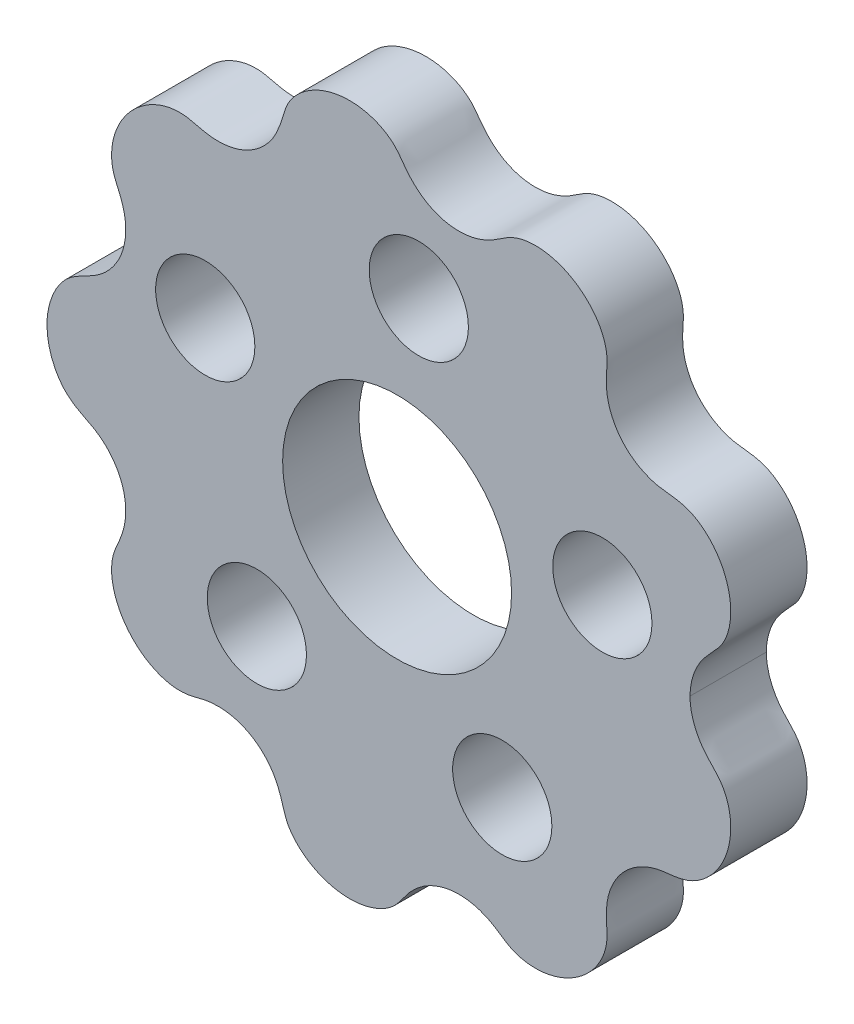
from build123d import *

# Parameters (mm, degrees)
SKETCH_1_R          = 6
EXTRUDE_1_DEPTH     = 4
SKETCH_2_R          = 2.6
CUT_EXTRUDE_1_DEPTH = 4
CUT_EXTRUDE_2_DEPTH = 20


with BuildPart() as part:
    # 草图1 → 凸台-拉伸1 (new body)
    with BuildSketch(Plane.XY):
        with BuildLine():
            add(Edge.make_bspline(
                [(15.500012348, 0), (15.500645056, -0.110945579), (15.512244846, -0.333708134), (15.56080203, -0.665755528), (15.686127898, -1.095543655), (15.861199112, -1.486039477), (16.07234193, -1.834330022), (16.308329582, -2.140469508), (16.554971715, -2.411142214), (16.831486095, -2.680258156), (17.09417526, -2.991849508), (17.318310393, -3.376025869), (17.493414378, -3.823344747), (17.600433494, -4.292089882), (17.644680388, -4.770032347), (17.628438972, -5.345442688), (17.511433644, -6.009073131), (17.278169805, -6.64415923), (16.937084367, -7.226794616), (16.575099706, -7.677002473), (16.230913701, -8.012641761), (15.844660445, -8.299708218), (15.420312172, -8.526649182), (15.041200514, -8.657072274), (14.727411454, -8.716357887), (14.475396299, -8.743253426), (14.287840755, -8.761378707), (14.053780681, -8.78754437), (13.774476702, -8.831854759), (13.435631669, -8.913065786), (13.046475639, -9.054518572), (12.661901116, -9.252728428), (12.293359231, -9.51266783), (11.884847729, -9.896613005), (11.554140655, -10.350120451), (11.313867772, -10.855204363), (11.174534113, -11.372142401), (11.117745702, -11.772455328), (11.105580832, -12.15666376), (11.123538194, -12.5208422), (11.161632052, -12.902801573), (11.156513572, -13.307609415), (11.077036824, -13.743232828), (10.919642656, -14.196363601), (10.697252801, -14.621676142), (10.421334976, -15.013428486), (10.038624904, -15.438358823), (9.519879354, -15.869092133), (8.927602604, -16.20436412), (8.28296764, -16.42933205), (7.709837342, -16.5363703), (7.233957857, -16.56641967), (6.757848942, -16.533391128), (6.291654266, -16.431205387), (5.918806602, -16.283724895), (5.639283103, -16.121815596), (5.429189454, -15.97884859), (5.275520034, -15.873677026), (5.08115039, -15.745699964), (4.840646937, -15.603383924), (4.528246746, -15.449991133), (4.135785298, -15.310075701), (3.706914344, -15.21711311), (3.247358332, -15.184013627), (2.683616627, -15.224313987), (2.140357034, -15.368005564), (1.638214991, -15.606714116), (1.208281686, -15.914761357), (0.913691367, -16.184992229), (0.662262597, -16.470572297), (0.445813505, -16.759694454), (0.230880732, -17.073039045), (-0.033157525, -17.373910711), (-0.368153716, -17.648605439), (-0.768020687, -17.886570031), (-1.197742019, -18.065543824), (-1.646249026, -18.188095665), (-2.200564338, -18.271695312), (-2.860263372, -18.275882878), (-3.513707318, -18.16532789), (-4.137283921, -17.943611616), (-4.64139611, -17.677469631), (-5.034364446, -17.405892441), (-5.388929067, -17.084733218), (-5.692750717, -16.715459856), (-5.917926574, -16.335896793), (-6.063844811, -15.959590707), (-6.159018515, -15.588889837), (-6.264745664, -15.241187207), (-6.405191317, -14.884637032), (-6.592424605, -14.527795683), (-6.83291701, -14.179916823), (-7.131479128, -13.852998257), (-7.562146174, -13.49483271), (-8.05706918, -13.219964643), (-8.59778426, -13.042242616), (-9.141509134, -12.970482269), (-9.554297958, -12.968980709), (-9.897259393, -13.006571791), (-10.169778374, -13.05791326), (-10.394441717, -13.111355966), (-10.573432363, -13.157274149), (-10.81755935, -13.219185953), (-11.132458027, -13.275500509), (-11.53518174, -13.287679567), (-12.015391816, -13.223776598), (-12.480698875, -13.088905012), (-12.923149037, -12.892864291), (-13.423381512, -12.593604406), (-13.948700915, -12.161386427), (-14.388934988, -11.642342598), (-14.728215283, -11.056761927), (-14.939700346, -10.525268324), (-15.060904211, -10.068979736), (-15.12238338, -9.600221994), (-15.115836901, -9.127737278), (-15.042892864, -8.692577333), (-14.908282623, -8.306673996), (-14.740220709, -7.957832439), (-14.597927538, -7.618965375), (-14.477542028, -7.250368161), (-14.394399075, -6.850773435), (-14.350409232, -6.3116245), (-14.407649225, -5.749269062), (-14.569528538, -5.205860879), (-14.829729033, -4.703130394), (-15.0936632, -4.33263276), (-15.391939241, -4.017591627), (-15.711193803, -3.756589186), (-16.00068685, -3.568915687), (-16.244479863, -3.436538423), (-16.493001037, -3.313257547), (-16.763479178, -3.188383092), (-17.082150332, -3.007532312), (-17.425261485, -2.724866456), (-17.740378416, -2.369698261), (-18.000745754, -1.972409345), (-18.206889112, -1.545151716), (-18.392385524, -1.002108371), (-18.473867602, -0.558465841), (-18.499033816, -0.222693371), (-18.499997323, 0)],
                knots=[0.122949625, 0.122949625, 0.122949625, 0.122949625, 0.122949625, 0.128396608, 0.133889369, 0.139372934, 0.144856498, 0.14934603, 0.153835562, 0.158325094, 0.162814627, 0.168292898, 0.17377117, 0.180047296, 0.186323423, 0.191803347, 0.197283271, 0.208243119, 0.21926116, 0.22477018, 0.2302792, 0.236541517, 0.242803834, 0.24831051, 0.253817186, 0.256129694, 0.258442201, 0.260754709, 0.263067216, 0.267692231, 0.272317246, 0.27783198, 0.283346713, 0.288866947, 0.294387181, 0.30526522, 0.310695103, 0.316124986, 0.320596912, 0.325068837, 0.329540762, 0.334012688, 0.339439896, 0.344867103, 0.351176165, 0.357485227, 0.362911415, 0.368337604, 0.379189982, 0.390444514, 0.39607178, 0.401699045, 0.407747404, 0.413795762, 0.419420549, 0.425045336, 0.427330399, 0.429615462, 0.431900526, 0.434185589, 0.438755715, 0.443325841, 0.448958262, 0.454590682, 0.460230133, 0.465869584, 0.476610964, 0.481971727, 0.487332489, 0.491763254, 0.49619402, 0.500624785, 0.505055551, 0.510412088, 0.515768625, 0.521798169, 0.527827714, 0.53318598, 0.538544247, 0.54926078, 0.560078777, 0.565487776, 0.570896775, 0.577186447, 0.583476118, 0.58888578, 0.594295441, 0.598753624, 0.603211806, 0.607669989, 0.612128172, 0.617539855, 0.622951539, 0.628373602, 0.633795666, 0.644955124, 0.650528285, 0.656101446, 0.660636549, 0.665171653, 0.667439204, 0.669706756, 0.671974307, 0.674241859, 0.679807823, 0.685373788, 0.69165463, 0.697935473, 0.703503519, 0.709071566, 0.72020766, 0.731178828, 0.736664412, 0.742149996, 0.748227574, 0.754305152, 0.75979058, 0.765276008, 0.769783463, 0.774290918, 0.778798372, 0.783305827, 0.78879334, 0.794280853, 0.80527863, 0.810847908, 0.816417186, 0.821978545, 0.827539905, 0.832078373, 0.83661684, 0.838886074, 0.841155308, 0.845693775, 0.851249605, 0.856805435, 0.86286691, 0.868928385, 0.874484925, 0.880041465, 0.890974567, 0.890974567, 0.890974567, 0.890974567, 0.890974567], degree=4))
            add(Edge.make_bspline(
                [(15.500012348, 0), (15.500645056, 0.110945579), (15.512244846, 0.333708134), (15.56080203, 0.665755528), (15.686127898, 1.095543655), (15.861199112, 1.486039477), (16.07234193, 1.834330022), (16.308329582, 2.140469507), (16.554971715, 2.411142214), (16.831486095, 2.680258156), (17.09417526, 2.991849508), (17.318310393, 3.376025869), (17.493414378, 3.823344747), (17.600433494, 4.292089882), (17.644680388, 4.770032347), (17.628438972, 5.345442688), (17.511433644, 6.009073131), (17.278169805, 6.64415923), (16.937084367, 7.226794616), (16.575099706, 7.677002473), (16.230913701, 8.012641761), (15.844660445, 8.299708218), (15.420312172, 8.526649182), (15.041200514, 8.657072274), (14.727411454, 8.716357887), (14.475396299, 8.743253426), (14.287840755, 8.761378707), (14.053780681, 8.78754437), (13.774476702, 8.831854759), (13.435631669, 8.913065786), (13.046475639, 9.054518572), (12.661901116, 9.252728428), (12.293359231, 9.51266783), (11.884847729, 9.896613005), (11.554140655, 10.350120451), (11.313867772, 10.855204363), (11.174534113, 11.372142401), (11.117745702, 11.772455328), (11.105580832, 12.15666376), (11.123538194, 12.5208422), (11.161632052, 12.902801573), (11.156513572, 13.307609415), (11.077036824, 13.743232827), (10.919642656, 14.196363601), (10.697252801, 14.621676142), (10.421334976, 15.013428486), (10.038624904, 15.438358823), (9.519879354, 15.869092133), (8.927602604, 16.20436412), (8.28296764, 16.42933205), (7.709837342, 16.5363703), (7.233957857, 16.56641967), (6.757848942, 16.533391128), (6.291654266, 16.431205387), (5.918806602, 16.283724895), (5.639283102, 16.121815596), (5.429189454, 15.97884859), (5.275520034, 15.873677026), (5.08115039, 15.745699964), (4.840646937, 15.603383924), (4.528246746, 15.449991133), (4.135785298, 15.310075701), (3.706914344, 15.21711311), (3.247358332, 15.184013627), (2.683616627, 15.224313987), (2.140357034, 15.368005564), (1.638214991, 15.606714115), (1.208281686, 15.914761357), (0.913691367, 16.184992229), (0.662262596, 16.470572297), (0.445813505, 16.759694454), (0.230880731, 17.073039045), (-0.033157525, 17.373910711), (-0.368153716, 17.648605439), (-0.768020687, 17.886570031), (-1.197742019, 18.065543824), (-1.646249026, 18.188095665), (-2.200564338, 18.271695312), (-2.860263372, 18.275882877), (-3.513707318, 18.165327889), (-4.137283921, 17.943611616), (-4.64139611, 17.677469631), (-5.034364446, 17.405892441), (-5.388929067, 17.084733218), (-5.692750717, 16.715459856), (-5.917926574, 16.335896793), (-6.063844811, 15.959590707), (-6.159018515, 15.588889837), (-6.264745664, 15.241187207), (-6.405191317, 14.884637032), (-6.592424605, 14.527795683), (-6.83291701, 14.179916823), (-7.131479128, 13.852998256), (-7.562146174, 13.49483271), (-8.05706918, 13.219964643), (-8.59778426, 13.042242616), (-9.141509134, 12.970482269), (-9.554297958, 12.968980709), (-9.897259393, 13.006571791), (-10.169778374, 13.05791326), (-10.394441717, 13.111355966), (-10.573432363, 13.157274149), (-10.81755935, 13.219185953), (-11.132458027, 13.275500509), (-11.53518174, 13.287679567), (-12.015391816, 13.223776598), (-12.480698875, 13.088905011), (-12.923149037, 12.892864291), (-13.423381512, 12.593604406), (-13.948700915, 12.161386427), (-14.388934988, 11.642342598), (-14.728215283, 11.056761927), (-14.939700346, 10.525268324), (-15.060904211, 10.068979736), (-15.12238338, 9.600221993), (-15.115836901, 9.127737278), (-15.042892864, 8.692577333), (-14.908282623, 8.306673996), (-14.740220709, 7.957832438), (-14.597927538, 7.618965375), (-14.477542028, 7.250368161), (-14.394399075, 6.850773435), (-14.350409232, 6.3116245), (-14.407649225, 5.749269062), (-14.569528538, 5.205860879), (-14.829729033, 4.703130394), (-15.0936632, 4.33263276), (-15.391939241, 4.017591627), (-15.711193803, 3.756589186), (-16.00068685, 3.568915687), (-16.244479863, 3.436538423), (-16.493001037, 3.313257547), (-16.763479178, 3.188383092), (-17.082150332, 3.007532312), (-17.425261485, 2.724866456), (-17.740378416, 2.369698261), (-18.000745754, 1.972409345), (-18.206889112, 1.545151716), (-18.392385523, 1.002108371), (-18.473867602, 0.558465841), (-18.499033816, 0.222693371), (-18.499997323, 0)],
                knots=[0.122949625, 0.122949625, 0.122949625, 0.122949625, 0.122949625, 0.128396608, 0.133889369, 0.139372934, 0.144856498, 0.14934603, 0.153835562, 0.158325094, 0.162814627, 0.168292898, 0.17377117, 0.180047296, 0.186323423, 0.191803347, 0.197283271, 0.208243119, 0.21926116, 0.22477018, 0.2302792, 0.236541517, 0.242803834, 0.24831051, 0.253817186, 0.256129694, 0.258442201, 0.260754709, 0.263067216, 0.267692231, 0.272317246, 0.27783198, 0.283346713, 0.288866947, 0.294387181, 0.30526522, 0.310695103, 0.316124986, 0.320596912, 0.325068837, 0.329540762, 0.334012688, 0.339439896, 0.344867103, 0.351176165, 0.357485227, 0.362911415, 0.368337604, 0.379189982, 0.390444514, 0.39607178, 0.401699045, 0.407747404, 0.413795762, 0.419420549, 0.425045336, 0.427330399, 0.429615462, 0.431900526, 0.434185589, 0.438755715, 0.443325841, 0.448958262, 0.454590682, 0.460230133, 0.465869584, 0.476610964, 0.481971727, 0.487332489, 0.491763254, 0.49619402, 0.500624785, 0.505055551, 0.510412088, 0.515768625, 0.521798169, 0.527827714, 0.53318598, 0.538544247, 0.54926078, 0.560078777, 0.565487776, 0.570896775, 0.577186447, 0.583476118, 0.58888578, 0.594295441, 0.598753624, 0.603211806, 0.607669989, 0.612128172, 0.617539855, 0.622951539, 0.628373602, 0.633795666, 0.644955124, 0.650528285, 0.656101446, 0.660636549, 0.665171653, 0.667439204, 0.669706756, 0.671974307, 0.674241859, 0.679807823, 0.685373788, 0.69165463, 0.697935473, 0.703503519, 0.709071566, 0.72020766, 0.731178828, 0.736664412, 0.742149996, 0.748227574, 0.754305152, 0.75979058, 0.765276008, 0.769783463, 0.774290918, 0.778798372, 0.783305827, 0.78879334, 0.794280853, 0.80527863, 0.810847908, 0.816417186, 0.821978545, 0.827539905, 0.832078373, 0.83661684, 0.838886074, 0.841155308, 0.845693775, 0.851249605, 0.856805435, 0.86286691, 0.868928385, 0.874484925, 0.880041465, 0.890974567, 0.890974567, 0.890974567, 0.890974567, 0.890974567], degree=4))
        make_face()
        Circle(SKETCH_1_R, mode=Mode.SUBTRACT)
    extrude(amount=EXTRUDE_1_DEPTH)

    # 草图2 → 切除-拉伸1 (cut)
    with BuildSketch(Plane.XY.offset(4)):
        with Locations((5.511431327, -9.519670411)):
            Circle(SKETCH_2_R)
        with Locations((-7.350618634, -8.183422615)):
            Circle(SKETCH_2_R)
        with Locations((-10.054363481, 4.46203709)):
            Circle(SKETCH_2_R)
        with Locations((1.136680267, 10.941113196)):
            Circle(SKETCH_2_R)
        with Locations((10.75687052, 2.29994274)):
            Circle(SKETCH_2_R)
    extrude(amount=-CUT_EXTRUDE_1_DEPTH, mode=Mode.SUBTRACT)

    # 草图3 → 切除-拉伸2 (cut)
    with BuildSketch(Plane.XY.offset(4)):
        with BuildLine():
            add(Edge.make_bspline(
                [(-18.499997323, 0), (-18.499033816, -0.222693371), (-18.473867602, -0.558465841), (-18.392385524, -1.002108371), (-18.206889112, -1.545151716), (-18.000745754, -1.972409345), (-17.740378416, -2.369698261), (-17.425261485, -2.724866456), (-17.082150332, -3.007532312), (-16.763479178, -3.188383092), (-16.493001037, -3.313257547), (-16.244479863, -3.436538423), (-16.00068685, -3.568915687), (-15.711193803, -3.756589186), (-15.391939241, -4.017591627), (-15.0936632, -4.33263276), (-14.829729033, -4.703130394), (-14.569528538, -5.205860879), (-14.407649225, -5.749269062), (-14.350409232, -6.3116245), (-14.394399075, -6.850773435), (-14.477542028, -7.250368161), (-14.597927538, -7.618965375), (-14.740220709, -7.957832439), (-14.908282623, -8.306673996), (-15.042892864, -8.692577333), (-15.115836901, -9.127737278), (-15.12238338, -9.600221994), (-15.060904211, -10.068979736), (-14.939700346, -10.525268324), (-14.728215283, -11.056761927), (-14.388934988, -11.642342598), (-13.948700915, -12.161386427), (-13.423381512, -12.593604406), (-12.923149037, -12.892864291), (-12.480698875, -13.088905012), (-12.015391816, -13.223776598), (-11.53518174, -13.287679567), (-11.132458027, -13.275500509), (-10.81755935, -13.219185953), (-10.573432363, -13.157274149), (-10.394441717, -13.111355966), (-10.169778374, -13.05791326), (-9.897259393, -13.006571791), (-9.554297958, -12.968980709), (-9.141509134, -12.970482269), (-8.59778426, -13.042242616), (-8.05706918, -13.219964643), (-7.562146174, -13.49483271), (-7.131479128, -13.852998257), (-6.83291701, -14.179916823), (-6.592424605, -14.527795683), (-6.405191317, -14.884637032), (-6.264745664, -15.241187207), (-6.159018515, -15.588889837), (-6.063844811, -15.959590707), (-5.917926574, -16.335896793), (-5.692750717, -16.715459856), (-5.388929067, -17.084733218), (-5.034364446, -17.405892441), (-4.64139611, -17.677469631), (-4.137283921, -17.943611616), (-3.513707318, -18.16532789), (-2.860263372, -18.275882878), (-2.200564338, -18.271695312), (-1.646249026, -18.188095665), (-1.197742019, -18.065543824), (-0.768020687, -17.886570031), (-0.368153716, -17.648605439), (-0.033157525, -17.373910711), (0.230880732, -17.073039045), (0.445813505, -16.759694454), (0.662262597, -16.470572297), (0.913691367, -16.184992229), (1.208281686, -15.914761357), (1.638214991, -15.606714116), (2.140357034, -15.368005564), (2.683616627, -15.224313987), (3.247358332, -15.184013627), (3.706914344, -15.21711311), (4.135785298, -15.310075701), (4.528246746, -15.449991133), (4.840646937, -15.603383924), (5.08115039, -15.745699964), (5.275520034, -15.873677026), (5.429189454, -15.97884859), (5.639283103, -16.121815596), (5.918806602, -16.283724895), (6.291654266, -16.431205387), (6.757848942, -16.533391128), (7.233957857, -16.56641967), (7.709837342, -16.5363703), (8.28296764, -16.42933205), (8.927602604, -16.20436412), (9.519879354, -15.869092133), (10.038624904, -15.438358823), (10.421334976, -15.013428486), (10.697252801, -14.621676142), (10.919642656, -14.196363601), (11.077036824, -13.743232828), (11.156513572, -13.307609415), (11.161632052, -12.902801573), (11.123538194, -12.5208422), (11.105580832, -12.15666376), (11.117745702, -11.772455328), (11.174534113, -11.372142401), (11.313867772, -10.855204363), (11.554140655, -10.350120451), (11.884847729, -9.896613005), (12.293359231, -9.51266783), (12.661901116, -9.252728428), (13.046475639, -9.054518572), (13.435631669, -8.913065786), (13.774476702, -8.831854759), (14.053780681, -8.78754437), (14.287840755, -8.761378707), (14.475396299, -8.743253426), (14.727411454, -8.716357887), (15.041200514, -8.657072274), (15.420312172, -8.526649182), (15.844660445, -8.299708218), (16.230913701, -8.012641761), (16.575099706, -7.677002473), (16.937084367, -7.226794616), (17.278169805, -6.64415923), (17.511433644, -6.009073131), (17.628438972, -5.345442688), (17.644680388, -4.770032347), (17.600433494, -4.292089882), (17.493414378, -3.823344747), (17.318310393, -3.376025869), (17.09417526, -2.991849508), (16.831486095, -2.680258156), (16.554971715, -2.411142214), (16.308329582, -2.140469508), (16.07234193, -1.834330022), (15.861199112, -1.486039477), (15.686127898, -1.095543655), (15.56080203, -0.665755528), (15.512244846, -0.333708134), (15.500645056, -0.110945579), (15.500012348, 0)],
                knots=[0.122949625, 0.122949625, 0.122949625, 0.122949625, 0.122949625, 0.133882727, 0.139439267, 0.144995807, 0.151057282, 0.157118757, 0.162674587, 0.168230417, 0.172768884, 0.175038118, 0.177307352, 0.181845819, 0.186384287, 0.191945647, 0.197507006, 0.203076284, 0.208645562, 0.219643339, 0.225130852, 0.230618365, 0.23512582, 0.239633274, 0.244140729, 0.248648184, 0.254133612, 0.25961904, 0.265696618, 0.271774196, 0.27725978, 0.282745364, 0.293716532, 0.304852626, 0.310420673, 0.315988719, 0.322269562, 0.328550404, 0.334116369, 0.339682333, 0.341949885, 0.344217436, 0.346484988, 0.348752539, 0.353287643, 0.357822746, 0.363395907, 0.368969068, 0.380128526, 0.38555059, 0.390972653, 0.396384337, 0.40179602, 0.406254203, 0.410712385, 0.415170568, 0.419628751, 0.425038412, 0.430448073, 0.436737745, 0.443027417, 0.448436416, 0.453845414, 0.464663412, 0.475379945, 0.480738212, 0.486096478, 0.492126023, 0.498155567, 0.503512104, 0.508868641, 0.513299407, 0.517730172, 0.522160938, 0.526591703, 0.531952465, 0.537313228, 0.548054608, 0.553694059, 0.55933351, 0.56496593, 0.570598351, 0.575168477, 0.579738603, 0.582023666, 0.58430873, 0.586593793, 0.588878856, 0.594503643, 0.60012843, 0.606176788, 0.612225147, 0.617852412, 0.623479678, 0.63473421, 0.645586588, 0.651012776, 0.656438965, 0.662748027, 0.669057089, 0.674484296, 0.679911504, 0.68438343, 0.688855355, 0.69332728, 0.697799206, 0.703229089, 0.708658972, 0.719537011, 0.725057245, 0.730577479, 0.736092212, 0.741606946, 0.746231961, 0.750856976, 0.753169483, 0.755481991, 0.757794498, 0.760107006, 0.765613682, 0.771120358, 0.777382675, 0.783644991, 0.789154012, 0.794663032, 0.805681073, 0.816640921, 0.822120845, 0.827600769, 0.833876896, 0.840153022, 0.845631294, 0.851109565, 0.855599097, 0.86008863, 0.864578162, 0.869067694, 0.874551258, 0.880034823, 0.885527584, 0.890974567, 0.890974567, 0.890974567, 0.890974567, 0.890974567], degree=4))
            add(Edge.make_bspline(
                [(15.500012348, 0), (15.500645056, 0.110945579), (15.512244846, 0.333708134), (15.56080203, 0.665755528), (15.686127898, 1.095543655), (15.861199112, 1.486039477), (16.07234193, 1.834330022), (16.308329582, 2.140469507), (16.554971715, 2.411142214), (16.831486095, 2.680258156), (17.09417526, 2.991849508), (17.318310393, 3.376025869), (17.493414378, 3.823344747), (17.600433494, 4.292089882), (17.644680388, 4.770032347), (17.628438972, 5.345442688), (17.511433644, 6.009073131), (17.278169805, 6.64415923), (16.937084367, 7.226794616), (16.575099706, 7.677002473), (16.230913701, 8.012641761), (15.844660445, 8.299708218), (15.420312172, 8.526649182), (15.041200514, 8.657072274), (14.727411454, 8.716357887), (14.475396299, 8.743253426), (14.287840755, 8.761378707), (14.053780681, 8.78754437), (13.774476702, 8.831854759), (13.435631669, 8.913065786), (13.046475639, 9.054518572), (12.661901116, 9.252728428), (12.293359231, 9.51266783), (11.884847729, 9.896613005), (11.554140655, 10.350120451), (11.313867772, 10.855204363), (11.174534113, 11.372142401), (11.117745702, 11.772455328), (11.105580832, 12.15666376), (11.123538194, 12.5208422), (11.161632052, 12.902801573), (11.156513572, 13.307609415), (11.077036824, 13.743232827), (10.919642656, 14.196363601), (10.697252801, 14.621676142), (10.421334976, 15.013428486), (10.038624904, 15.438358823), (9.519879354, 15.869092133), (8.927602604, 16.20436412), (8.28296764, 16.42933205), (7.709837342, 16.5363703), (7.233957857, 16.56641967), (6.757848942, 16.533391128), (6.291654266, 16.431205387), (5.918806602, 16.283724895), (5.639283102, 16.121815596), (5.429189454, 15.97884859), (5.275520034, 15.873677026), (5.08115039, 15.745699964), (4.840646937, 15.603383924), (4.528246746, 15.449991133), (4.135785298, 15.310075701), (3.706914344, 15.21711311), (3.247358332, 15.184013627), (2.683616627, 15.224313987), (2.140357034, 15.368005564), (1.638214991, 15.606714115), (1.208281686, 15.914761357), (0.913691367, 16.184992229), (0.662262596, 16.470572297), (0.445813505, 16.759694454), (0.230880731, 17.073039045), (-0.033157525, 17.373910711), (-0.368153716, 17.648605439), (-0.768020687, 17.886570031), (-1.197742019, 18.065543824), (-1.646249026, 18.188095665), (-2.200564338, 18.271695312), (-2.860263372, 18.275882877), (-3.513707318, 18.165327889), (-4.137283921, 17.943611616), (-4.64139611, 17.677469631), (-5.034364446, 17.405892441), (-5.388929067, 17.084733218), (-5.692750717, 16.715459856), (-5.917926574, 16.335896793), (-6.063844811, 15.959590707), (-6.159018515, 15.588889837), (-6.264745664, 15.241187207), (-6.405191317, 14.884637032), (-6.592424605, 14.527795683), (-6.83291701, 14.179916823), (-7.131479128, 13.852998256), (-7.562146174, 13.49483271), (-8.05706918, 13.219964643), (-8.59778426, 13.042242616), (-9.141509134, 12.970482269), (-9.554297958, 12.968980709), (-9.897259393, 13.006571791), (-10.169778374, 13.05791326), (-10.394441717, 13.111355966), (-10.573432363, 13.157274149), (-10.81755935, 13.219185953), (-11.132458027, 13.275500509), (-11.53518174, 13.287679567), (-12.015391816, 13.223776598), (-12.480698875, 13.088905011), (-12.923149037, 12.892864291), (-13.423381512, 12.593604406), (-13.948700915, 12.161386427), (-14.388934988, 11.642342598), (-14.728215283, 11.056761927), (-14.939700346, 10.525268324), (-15.060904211, 10.068979736), (-15.12238338, 9.600221993), (-15.115836901, 9.127737278), (-15.042892864, 8.692577333), (-14.908282623, 8.306673996), (-14.740220709, 7.957832438), (-14.597927538, 7.618965375), (-14.477542028, 7.250368161), (-14.394399075, 6.850773435), (-14.350409232, 6.3116245), (-14.407649225, 5.749269062), (-14.569528538, 5.205860879), (-14.829729033, 4.703130394), (-15.0936632, 4.33263276), (-15.391939241, 4.017591627), (-15.711193803, 3.756589186), (-16.00068685, 3.568915687), (-16.244479863, 3.436538423), (-16.493001037, 3.313257547), (-16.763479178, 3.188383092), (-17.082150332, 3.007532312), (-17.425261485, 2.724866456), (-17.740378416, 2.369698261), (-18.000745754, 1.972409345), (-18.206889112, 1.545151716), (-18.392385523, 1.002108371), (-18.473867602, 0.558465841), (-18.499033816, 0.222693371), (-18.499997323, 0)],
                knots=[0.122949625, 0.122949625, 0.122949625, 0.122949625, 0.122949625, 0.128396608, 0.133889369, 0.139372934, 0.144856498, 0.14934603, 0.153835562, 0.158325094, 0.162814627, 0.168292898, 0.17377117, 0.180047296, 0.186323423, 0.191803347, 0.197283271, 0.208243119, 0.21926116, 0.22477018, 0.2302792, 0.236541517, 0.242803834, 0.24831051, 0.253817186, 0.256129694, 0.258442201, 0.260754709, 0.263067216, 0.267692231, 0.272317246, 0.27783198, 0.283346713, 0.288866947, 0.294387181, 0.30526522, 0.310695103, 0.316124986, 0.320596912, 0.325068837, 0.329540762, 0.334012688, 0.339439896, 0.344867103, 0.351176165, 0.357485227, 0.362911415, 0.368337604, 0.379189982, 0.390444514, 0.39607178, 0.401699045, 0.407747404, 0.413795762, 0.419420549, 0.425045336, 0.427330399, 0.429615462, 0.431900526, 0.434185589, 0.438755715, 0.443325841, 0.448958262, 0.454590682, 0.460230133, 0.465869584, 0.476610964, 0.481971727, 0.487332489, 0.491763254, 0.49619402, 0.500624785, 0.505055551, 0.510412088, 0.515768625, 0.521798169, 0.527827714, 0.53318598, 0.538544247, 0.54926078, 0.560078777, 0.565487776, 0.570896775, 0.577186447, 0.583476118, 0.58888578, 0.594295441, 0.598753624, 0.603211806, 0.607669989, 0.612128172, 0.617539855, 0.622951539, 0.628373602, 0.633795666, 0.644955124, 0.650528285, 0.656101446, 0.660636549, 0.665171653, 0.667439204, 0.669706756, 0.671974307, 0.674241859, 0.679807823, 0.685373788, 0.69165463, 0.697935473, 0.703503519, 0.709071566, 0.72020766, 0.731178828, 0.736664412, 0.742149996, 0.748227574, 0.754305152, 0.75979058, 0.765276008, 0.769783463, 0.774290918, 0.778798372, 0.783305827, 0.78879334, 0.794280853, 0.80527863, 0.810847908, 0.816417186, 0.821978545, 0.827539905, 0.832078373, 0.83661684, 0.838886074, 0.841155308, 0.845693775, 0.851249605, 0.856805435, 0.86286691, 0.868928385, 0.874484925, 0.880041465, 0.890974567, 0.890974567, 0.890974567, 0.890974567, 0.890974567], degree=4))
        make_face()
        with BuildLine():
            add(Edge.make_bspline(
                [(-18.349995867, 0), (-18.347207588, -0.621463833), (-18.123084894, -1.569111281), (-17.390355161, -2.608310483), (-16.629881809, -3.110176902), (-15.696535847, -3.525486338), (-14.936662856, -4.230172354), (-14.409603244, -5.119897129), (-14.180365753, -6.130476952), (-14.256223651, -7.160576512), (-14.576725637, -7.9605452), (-14.83947909, -8.532745553), (-14.981471185, -9.130938966), (-14.965258823, -9.919033589), (-14.692597481, -10.825925719), (-14.210384417, -11.64340923), (-13.552575443, -12.328523687), (-12.755800531, -12.839672934), (-11.851343441, -13.136282677), (-10.932030843, -13.13559567), (-9.984805369, -12.822843418), (-8.947091115, -12.799770263), (-7.950827736, -13.074274697), (-7.082916293, -13.64076339), (-6.422666216, -14.436011632), (-6.036302316, -15.398027287), (-5.816880404, -16.32088914), (-5.235715048, -17.064270347), (-4.479032139, -17.631445857), (-3.310012727, -18.11600728), (-2.018535663, -18.179454669), (-0.820712899, -17.777845648), (-0.048643425, -17.249042025), (0.464360042, -16.430902117), (1.188264326, -15.687499575), (2.09718097, -15.195884371), (3.114670815, -14.997628134), (4.141164507, -15.115361573), (5.093193575, -15.529428954), (5.862146977, -16.140088396), (6.748963611, -16.411836918), (7.698433372, -16.414865137), (8.92275606, -16.10252946), (9.992215697, -15.374349297), (10.716531218, -14.340817971), (10.976306666, -13.596453339), (11.018022218, -12.985319907), (10.953786197, -12.345733742), (10.960994127, -11.139565084), (11.590893859, -9.858431853), (12.687771995, -9.022174508), (13.657191615, -8.653867558), (14.667249147, -8.608575557), (15.541249393, -8.344917328), (16.307625058, -7.776819937), (17.100185022, -6.796042563), (17.515919511, -5.570195379), (17.479697635, -4.307449252), (17.249943642, -3.553871277), (16.933377633, -3.023760673), (16.512315624, -2.568786167), (15.678369596, -1.70608269), (15.353839042, -0.671439846), (15.350009909, 0)],
                knots=[0.122957885, 0.122957885, 0.122957885, 0.122957885, 0.146958734, 0.158959159, 0.170959584, 0.182960009, 0.194960433, 0.206960858, 0.218961283, 0.230961707, 0.242962132, 0.248962344, 0.254962557, 0.266962982, 0.278963406, 0.290963831, 0.302964256, 0.31496468, 0.326965105, 0.33896553, 0.350965954, 0.362966379, 0.374966804, 0.386967229, 0.398967653, 0.410968078, 0.422968503, 0.434968927, 0.446969352, 0.458969777, 0.482970626, 0.494971051, 0.506971476, 0.5189719, 0.530972325, 0.54297275, 0.554973175, 0.566973599, 0.578974024, 0.590974449, 0.602974873, 0.614975298, 0.626975723, 0.650976572, 0.662976997, 0.674977422, 0.680977634, 0.686977846, 0.698978271, 0.72297912, 0.734979545, 0.74697997, 0.758980395, 0.770980819, 0.782981244, 0.794981669, 0.818982518, 0.830982943, 0.842983368, 0.84898358, 0.854983792, 0.866984217, 0.890985066, 0.890985066, 0.890985066, 0.890985066], degree=3))
            add(Edge.make_bspline(
                [(15.350009909, 0), (15.353839042, 0.671439846), (15.678369596, 1.70608269), (16.512315624, 2.568786167), (16.933377633, 3.023760672), (17.249943642, 3.553871277), (17.479697635, 4.307449252), (17.515919511, 5.570195379), (17.100185022, 6.796042563), (16.307625058, 7.776819937), (15.541249393, 8.344917328), (14.667249147, 8.608575557), (13.657191615, 8.653867558), (12.687771996, 9.022174508), (11.590893859, 9.858431853), (10.960994127, 11.139565084), (10.953786197, 12.345733742), (11.018022218, 12.985319907), (10.976306666, 13.596453338), (10.716531218, 14.340817971), (9.992215697, 15.374349296), (8.92275606, 16.10252946), (7.698433372, 16.414865137), (6.748963612, 16.411836918), (5.862146977, 16.140088396), (5.093193575, 15.529428954), (4.141164507, 15.115361572), (3.114670815, 14.997628134), (2.097180971, 15.195884371), (1.188264326, 15.687499575), (0.464360042, 16.430902117), (-0.048643425, 17.249042025), (-0.820712898, 17.777845647), (-2.018535662, 18.179454669), (-3.310012727, 18.11600728), (-4.479032138, 17.631445857), (-5.235715047, 17.064270347), (-5.816880404, 16.32088914), (-6.036302316, 15.398027288), (-6.422666216, 14.436011632), (-7.082916292, 13.640763391), (-7.950827736, 13.074274697), (-8.947091115, 12.799770263), (-9.984805368, 12.822843418), (-10.932030842, 13.13559567), (-11.85134344, 13.136282677), (-12.75580053, 12.839672934), (-13.552575443, 12.328523687), (-14.210384416, 11.64340923), (-14.692597481, 10.82592572), (-14.965258823, 9.919033589), (-14.981471185, 9.130938967), (-14.83947909, 8.532745554), (-14.576725637, 7.960545201), (-14.256223651, 7.160576513), (-14.180365753, 6.130476953), (-14.409603244, 5.11989713), (-14.936662855, 4.230172354), (-15.696535846, 3.525486338), (-16.629881808, 3.110176902), (-17.39035516, 2.608310483), (-18.123084893, 1.569111282), (-18.347207588, 0.621463834), (-18.349995867, 0)],
                knots=[0.122939126, 0.122939126, 0.122939126, 0.122939126, 0.146939975, 0.1589404, 0.164940612, 0.170940824, 0.182941249, 0.194941674, 0.218942523, 0.230942948, 0.242943373, 0.254943797, 0.266944222, 0.278944647, 0.290945071, 0.314945921, 0.326946346, 0.332946558, 0.33894677, 0.350947195, 0.36294762, 0.386948469, 0.398948894, 0.410949319, 0.422949743, 0.434950168, 0.446950593, 0.458951017, 0.470951442, 0.482951867, 0.494952292, 0.506952716, 0.518953141, 0.530953566, 0.554954415, 0.56695484, 0.578955265, 0.590955689, 0.602956114, 0.614956539, 0.626956963, 0.638957388, 0.650957813, 0.662958237, 0.674958662, 0.686959087, 0.698959512, 0.710959936, 0.722960361, 0.734960786, 0.74696121, 0.758961635, 0.764961848, 0.77096206, 0.782962485, 0.794962909, 0.806963334, 0.818963759, 0.830964183, 0.842964608, 0.854965033, 0.866965458, 0.890966307, 0.890966307, 0.890966307, 0.890966307], degree=3))
        make_face(mode=Mode.SUBTRACT)
    extrude(amount=-CUT_EXTRUDE_2_DEPTH, mode=Mode.SUBTRACT)


solid = part.part
